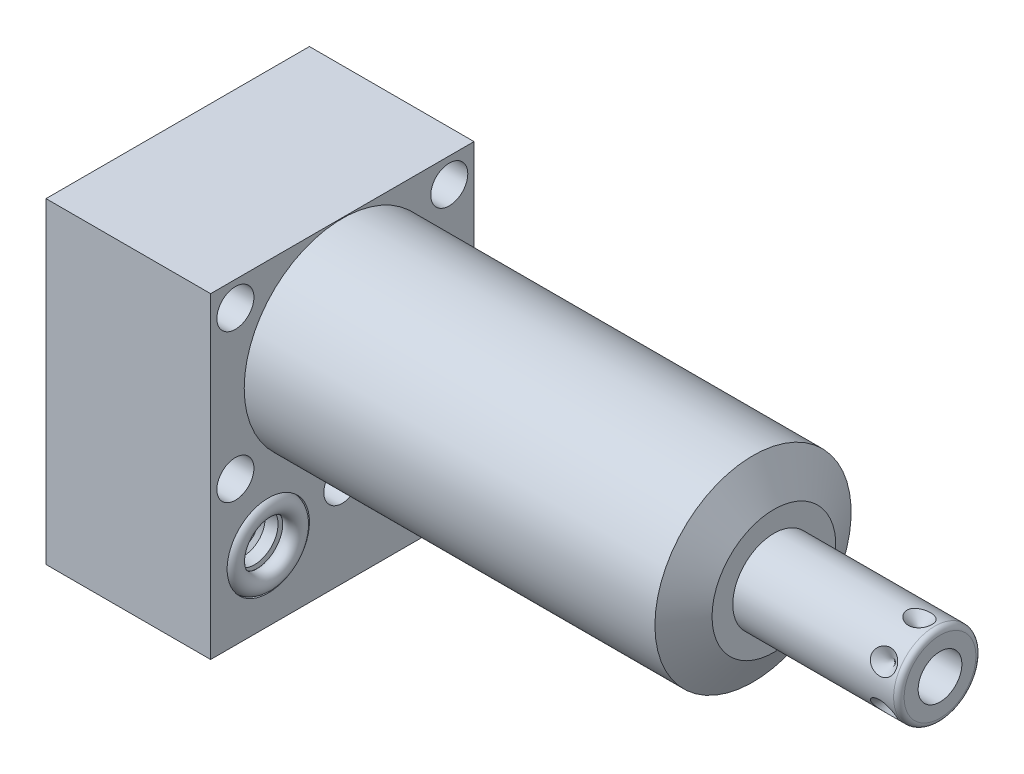
from build123d import *

# Parameters (mm, degrees)
SKETCH1_W           = 50.8
SKETCH1_H           = 61.1124
EXTRUDE1_DEPTH      = 83.2358
EXTRUDE1_DEPTH_BACK = 31.75
CUT_EXTRUDE1_REACH  = 85.236
SKETCH2_W           = 50.8
SKETCH2_H           = 61.1124
SKETCH2_R           = 18.923
SKETCH18_R          = 7.9375
CUT_EXTRUDE2_DEPTH  = 2.667
SKETCH19_R          = 7.9375
CUT_EXTRUDE3_DEPTH  = 2.667
SKETCH20_R          = 9.525
CUT_EXTRUDE4_DEPTH  = 0.254
SKETCH14_R          = 1.7653
SKETCH15_R          = 1.7653
CIRPATTERN1_COUNT   = 6
SKETCH21_W          = 3.5687
SKETCH21_H          = 31.75
HOLE1_AT_2_COUNT    = 2
HOLE1_AT_2_PITCH    = 44.445239059
HOLE1_AT_3_COUNT    = 2
HOLE1_AT_3_PITCH    = 28.5496
HOLE1_AT_4_COUNT    = 2
HOLE1_AT_4_PITCH    = 41.2496
HOLE1_AT_5_COUNT    = 2
HOLE1_AT_5_PITCH    = 50.165816652
LPATTERN1_COUNT     = 2
LPATTERN1_PITCH     = 28.5496


with BuildPart() as part:
    # Sketch1 → Extrude1 (new body, two sides)
    with BuildSketch(Plane(origin=(0, 0, 0), x_dir=(0, 0, -1), z_dir=(1, 0, 0))) as extrude1_sk:
        with Locations((0, -11.5062)):
            Rectangle(SKETCH1_W, SKETCH1_H)
    extrude(amount=EXTRUDE1_DEPTH)
    extrude(extrude1_sk.sketch, amount=-EXTRUDE1_DEPTH_BACK)

    # Sketch2 → Cut-Extrude1 (cut, up to next)
    with BuildSketch(Plane(origin=(0, 0, 0), x_dir=(0, 0, -1), z_dir=(1, 0, 0)), mode=Mode.PRIVATE) as cut_extrude1_sk1:
        with Locations((0, -11.5062)):
            Rectangle(SKETCH2_W, SKETCH2_H)
        Circle(SKETCH2_R, mode=Mode.SUBTRACT)
    cut_extrude1_tool1 = extrude(cut_extrude1_sk1.sketch, amount=CUT_EXTRUDE1_REACH, mode=Mode.PRIVATE) & part.part
    add(cut_extrude1_tool1.solids().sort_by_distance((0, 18.970531, 0))[0], mode=Mode.SUBTRACT)

    # Sketch3 → Cut-Revolve1 (revolve, cut)
    with BuildSketch(Plane.XY, mode=Mode.PRIVATE) as cut_revolve1_sk:
        Polygon((79.20300837, 18.923), (83.2358, 11.938), (83.2358, 18.923), align=None)
    revolve(cut_revolve1_sk.sketch.rotate(Axis((56.700168788, 0, 0), (1, 0, 0)), 90), axis=Axis((56.700168788, 0, 0), (1, 0, 0)), mode=Mode.SUBTRACT)  # turned: the seam where the file's is

    # S2D0002 → Cut-Revolve2 (revolve, cut)
    with BuildSketch(Plane(origin=(-29.083, -28.575, 14.2748), x_dir=(0, 1, 0), z_dir=(0, 0, 1)), mode=Mode.PRIVATE) as cut_revolve2_sk:
        Polygon((0, 0), (4.5466, 0), (4.106586662, -2.0701), (3.4544, -2.722286662), (3.4544, -13.97), (0, -13.97), align=None)
    revolve(cut_revolve2_sk.sketch.rotate(Axis((-14.4145, -28.575, 14.2748), (-1, 0, 0)), 90), axis=Axis((-14.4145, -28.575, 14.2748), (-1, 0, 0)), mode=Mode.SUBTRACT)  # turned: the seam where the file's is

    # Sketch5 → Cut-Revolve3 (revolve, cut)
    with BuildSketch(Plane(origin=(-29.083, -28.575, -14.2748), x_dir=(0, 1, 0), z_dir=(0, 0, 1)), mode=Mode.PRIVATE) as cut_revolve3_sk:
        Polygon((0, 0), (4.5466, 0), (4.106586662, -2.0701), (3.4544, -2.722286662), (3.4544, -13.97), (0, -13.97), align=None)
    revolve(cut_revolve3_sk.sketch.rotate(Axis((-14.4145, -28.575, -14.2748), (-1, 0, 0)), 90), axis=Axis((-14.4145, -28.575, -14.2748), (-1, 0, 0)), mode=Mode.SUBTRACT)  # turned: the seam where the file's is

    # Sketch6 → Cut-Revolve4 (revolve, cut)
    with BuildSketch(Plane(origin=(-2.667, -28.575, 14.2748), x_dir=(0, -1, 0), z_dir=(0, 0, 1)), mode=Mode.PRIVATE) as cut_revolve4_sk:
        Polygon((0, 0), (4.5466, 0), (4.106586662, -2.0701), (3.4544, -2.722286662), (3.4544, -12.192), (0, -12.192), align=None)
    revolve(cut_revolve4_sk.sketch.rotate(Axis((-15.4686, -28.575, 14.2748), (1, 0, 0)), 90), axis=Axis((-15.4686, -28.575, 14.2748), (1, 0, 0)), mode=Mode.SUBTRACT)  # turned: the seam where the file's is

    # Sketch7 → Cut-Revolve5 (revolve, cut)
    with BuildSketch(Plane(origin=(-2.667, -28.575, -14.2748), x_dir=(0, -1, 0), z_dir=(0, 0, 1)), mode=Mode.PRIVATE) as cut_revolve5_sk:
        Polygon((0, 0), (4.5466, 0), (4.106586662, -2.0701), (3.4544, -2.722286662), (3.4544, -12.192), (0, -12.192), align=None)
    revolve(cut_revolve5_sk.sketch.rotate(Axis((-15.4686, -28.575, -14.2748), (1, 0, 0)), 90), axis=Axis((-15.4686, -28.575, -14.2748), (1, 0, 0)), mode=Mode.SUBTRACT)  # turned: the seam where the file's is

    # Sketch18 → Cut-Extrude2 (cut)
    with BuildSketch(Plane.ZY.offset(31.75)):
        with Locations((-14.2748, -28.575)):
            Circle(SKETCH18_R)
        with Locations((14.2748, -28.575)):
            Circle(SKETCH18_R)
    extrude(amount=-CUT_EXTRUDE2_DEPTH, mode=Mode.SUBTRACT)

    # Sketch19 → Cut-Extrude3 (cut)
    with BuildSketch(Plane(origin=(0, 0, 0), x_dir=(0, 0, -1), z_dir=(1, 0, 0))):
        with Locations((-14.2748, -28.575)):
            Circle(SKETCH19_R)
        with Locations((14.2748, -28.575)):
            Circle(SKETCH19_R)
    extrude(amount=-CUT_EXTRUDE3_DEPTH, mode=Mode.SUBTRACT)

    # Sketch8 → Cut-Revolve6 (revolve, cut)
    with BuildSketch(Plane(origin=(-15.875, -43.688, 14.2748), x_dir=(-1, 0, 0), z_dir=(0, 0, 1)), mode=Mode.PRIVATE) as cut_revolve6_sk:
        Polygon((0, -1.8796), (6.1849, -1.8796), (5.642306865, -4.4323), (4.9784, -5.096206865), (4.9784, -20.9296), (0, -20.9296), align=None)
    revolve(cut_revolve6_sk.sketch.rotate(Axis((-15.875, -17.018, 14.2748), (0, -1, 0)), 270), axis=Axis((-15.875, -17.018, 14.2748), (0, -1, 0)), mode=Mode.SUBTRACT)  # turned: the seam where the file's is

    # Sketch9 → Cut-Revolve7 (revolve, cut)
    with BuildSketch(Plane(origin=(-15.875, -43.688, -14.2748), x_dir=(-1, 0, 0), z_dir=(0, 0, 1)), mode=Mode.PRIVATE) as cut_revolve7_sk:
        Polygon((0, -1.8796), (6.1849, -1.8796), (5.642306865, -4.4323), (4.9784, -5.096206865), (4.9784, -20.9296), (0, -20.9296), align=None)
    revolve(cut_revolve7_sk.sketch.rotate(Axis((-15.875, -17.018, -14.2748), (0, -1, 0)), 270), axis=Axis((-15.875, -17.018, -14.2748), (0, -1, 0)), mode=Mode.SUBTRACT)  # turned: the seam where the file's is

    # Sketch20 → Cut-Extrude4 (cut)
    with BuildSketch(Plane.XZ.offset(42.0624)):
        with Locations(Location((-15.875, 14.2748, 0), (0, 0, 270))):  # turned: the seam where the file's is
            Circle(SKETCH20_R)
        with Locations(Location((-15.875, -14.2748, 0), (0, 0, 270))):  # turned: the seam where the file's is
            Circle(SKETCH20_R)
    extrude(amount=-CUT_EXTRUDE4_DEPTH, mode=Mode.SUBTRACT)

    # Sketch10 → Revolve1 (revolve)
    with BuildSketch(Plane.XY, mode=Mode.PRIVATE) as revolve1_sk:
        with BuildLine():
            Line((83.2358, 0), (83.2358, 7.9375))
            Line((83.2358, 7.9375), (114.2492, 7.9375))
            ThreePointArc((114.2492, 7.9375), (114.96762049, 7.63992049), (115.2652, 6.9215))
            Line((115.2652, 6.9215), (115.2652, 0))
            Line((115.2652, 0), (83.2358, 0))
        make_face()
    revolve(revolve1_sk.sketch.rotate(Axis((59.59348, 0, 0), (1, 0, 0)), 90), axis=Axis((59.59348, 0, 0), (1, 0, 0)))  # turned: the seam where the file's is

    # S2D0001 → Cut-Revolve8 (revolve, cut)
    with BuildSketch(Plane(origin=(87.757, -4.2164, 0), x_dir=(0, -1, 0), z_dir=(0, 0, 1)), mode=Mode.PRIVATE) as cut_revolve8_sk:
        Polygon((0, 27.5082), (0, 12.2682), (-4.2164, 9.734731286), (-4.2164, 27.5082), align=None)
    revolve(cut_revolve8_sk.sketch.rotate(Axis((62.891960697, 0, 0), (1, 0, 0)), 270), axis=Axis((62.891960697, 0, 0), (1, 0, 0)), mode=Mode.SUBTRACT)  # turned: the seam where the file's is

    # Sketch16 → Cut-Revolve9 (revolve, cut)
    with BuildSketch(Plane(origin=(83.7946, -7.9375, 0), x_dir=(-1, 0, 0), z_dir=(0, 0, 1)), mode=Mode.PRIVATE) as cut_revolve9_sk:
        Polygon((-27.5082, 0), (-25.0952, 0), (-27.5082, -2.413), align=None)
    cut_revolve9 = revolve(cut_revolve9_sk.sketch.rotate(Axis((111.3028, -4.132061843, 0), (0, -1, 0)), 90), axis=Axis((111.3028, -4.132061843, 0), (0, -1, 0)), mode=Mode.SUBTRACT)  # turned: the seam where the file's is

    # CirPattern1: Cut-Revolve9 ×6 about axis
    cirpattern1_axis = Axis((83.2368, 0, 0), (-1, 0, 0))
    for i in range(1, CIRPATTERN1_COUNT):
        add(cut_revolve9.rotate(cirpattern1_axis, i * 360 / CIRPATTERN1_COUNT), mode=Mode.SUBTRACT)

    # Sketch21 → Hole1 (revolve, cut)
    with BuildSketch(Plane(origin=(0, 14.2748, 20.6248), x_dir=(0, 0, -1), z_dir=(0, 1, 0))):
        with Locations((1.78435, 15.875)):
            Rectangle(SKETCH21_W, SKETCH21_H)
    hole1 = revolve(axis=Axis((-110, 14.2748, 20.6248), (1, 0, 0)), mode=Mode.SUBTRACT)

    # Hole1 at 2: Hole1 ×2
    with Locations(*[Vector(0, -0.885809163, -0.464049703) * (i * HOLE1_AT_2_PITCH) for i in range(1, HOLE1_AT_2_COUNT)]):
        add(hole1, mode=Mode.SUBTRACT)

    # Hole1 at 3: Hole1 ×2
    with Locations(*[(0, -i * HOLE1_AT_3_PITCH, 0) for i in range(1, HOLE1_AT_3_COUNT)]):
        add(hole1, mode=Mode.SUBTRACT)

    # Hole1 at 4: Hole1 ×2
    with Locations(*[(0, 0, -i * HOLE1_AT_4_PITCH) for i in range(1, HOLE1_AT_4_COUNT)]):
        add(hole1, mode=Mode.SUBTRACT)

    # Hole1 at 5: Hole1 ×2
    with Locations(*[Vector(0, -0.569104659, -0.822265095) * (i * HOLE1_AT_5_PITCH) for i in range(1, HOLE1_AT_5_COUNT)]):
        add(hole1, mode=Mode.SUBTRACT)


with BuildPart() as body_2:
    # Sketch14 → Revolve2 (revolve)
    with BuildSketch(Plane(origin=(0, -28.575, -14.2748), x_dir=(0, 0, -1), z_dir=(0, -1, 0)), mode=Mode.PRIVATE) as revolve2_sk:
        with Locations((6.1722, -0.9017)):
            Circle(SKETCH14_R)
    revolve2 = revolve(revolve2_sk.sketch.rotate(Axis((-2.84353, -28.575, -14.2748), (1, 0, 0)), 180), axis=Axis((-2.84353, -28.575, -14.2748), (1, 0, 0)))  # turned: the seam where the file's is


with BuildPart() as body_3:
    # Sketch15 → Revolve3 (revolve)
    with BuildSketch(Plane(origin=(0, -28.575, -14.2748), x_dir=(0, 0, -1), z_dir=(0, -1, 0)), mode=Mode.PRIVATE) as revolve3_sk:
        with Locations((6.1722, -30.8483)):
            Circle(SKETCH15_R)
    revolve3 = revolve(revolve3_sk.sketch.rotate(Axis((-32.79013, -28.575, -14.2748), (1, 0, 0)), 180), axis=Axis((-32.79013, -28.575, -14.2748), (1, 0, 0)))  # turned: the seam where the file's is


with BuildPart() as lpattern1_1:
    # LPattern1: Revolve2, Revolve3 ×2
    with Locations(*[(0, 0, i * LPATTERN1_PITCH) for i in range(1, LPATTERN1_COUNT)]):
        add(revolve2)
        add(revolve3)


solid = Compound([part.part, body_2.part, body_3.part, lpattern1_1.part])
